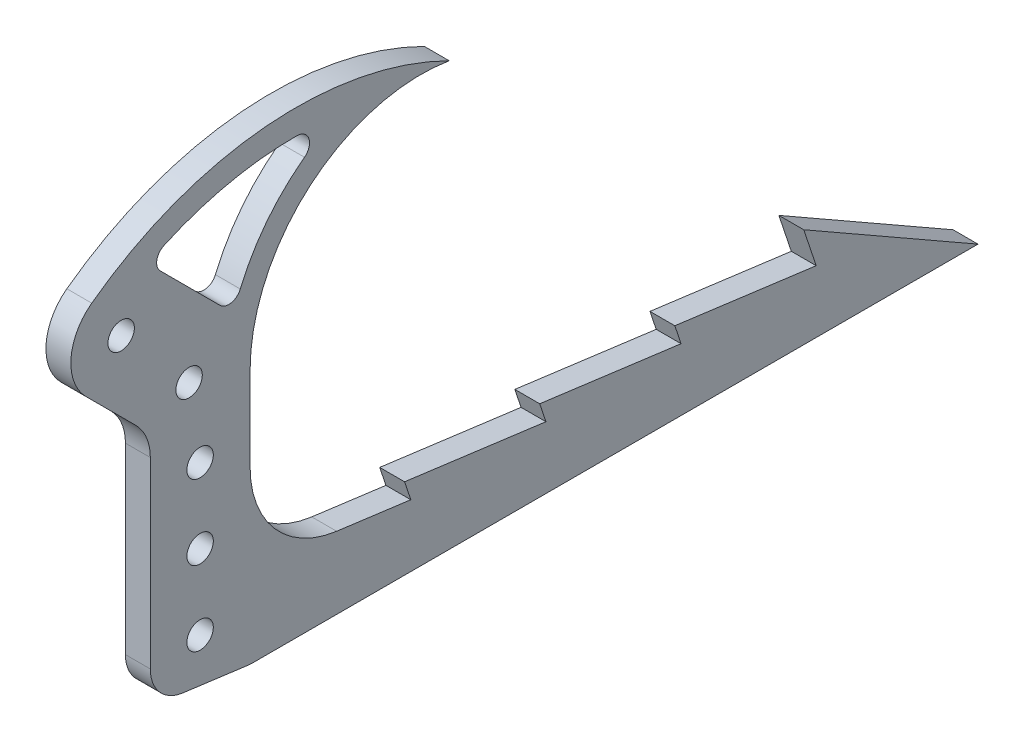
from build123d import *

# Parameters (mm, degrees)
SKETCH1_R                   = 19.05
BOSS_EXTRUDE1_DEPTH         = 12.7
FILLET1_R                   = 25.4
FILLET2_R                   = 50.8
F_1_2_CLEARANCE_HOLE1_D     = 13.49248
F_1_2_CLEARANCE_HOLE1_DEPTH = 38.1
F_1_2_CLEARANCE_HOLE1_TIP   = 4.053549943
SKETCH4_R                   = 19.05
CUT_EXTRUDE1_DEPTH          = 13.7
BOSS_EXTRUDE2_DEPTH         = 12.7
FILLET3_R                   = 19.05
FILLET4_R                   = 50.8
BOSS_EXTRUDE3_DEPTH         = 12.7
CUT_EXTRUDE2_DEPTH          = 13.7
FILLET7_R                   = 6.35


with BuildPart() as part:
    # Sketch1 → Boss-Extrude1 (new body)
    with BuildSketch(Plane(origin=(0, 0, 0), x_dir=(0, 0, -1), z_dir=(1, 0, 0))):
        with BuildLine():
            Line((390.630407277, -109.766978243), (305.29908743, -24.435658396))
            Line((305.29908743, -24.435658396), (12.395871839, 49.264412727))
            ThreePointArc((12.395871839, 49.264412727), (-49.470959365, 11.544010545), (-10.688712274, -49.662777107))
            Line((-10.688712274, -49.662777107), (281.610658396, -75.235658396))
            Line((281.610658396, -75.235658396), (339.725, -133.35))
            Line((339.725, -133.35), (339.725, -254))
            Line((339.725, -254), (390.630407277, -254))
            Line((390.630407277, -254), (390.630407277, -109.766978243))
        make_face()
        Circle(SKETCH1_R, mode=Mode.SUBTRACT)
    extrude(amount=BOSS_EXTRUDE1_DEPTH)

    # Fillet1
    fillet1_edges = [part.edges().sort_by_distance(p)[0] for p in [
        (6.35, -133.35, -339.725),
        (6.35, -75.235658396, -281.610658396),
    ]]
    fillet(fillet1_edges, radius=FILLET1_R)

    # Fillet2
    fillet2_edges = [part.edges().sort_by_distance(p)[0] for p in [
        (6.35, -24.435658396, -305.29908743),
        (6.35, -109.766978243, -390.630407277),
    ]]
    fillet(fillet2_edges, radius=FILLET2_R)

    # 1/2 Clearance Hole1
    with Locations(Plane(origin=(12.7, 0, 0), x_dir=(0, 0, -1), z_dir=(1, 0, 0))):
        with Locations((365.125, -234.95), (365.125, -196.85), (365.125, -158.75), (359.5071206, -120.65), (324.846024484, -82.55)):
            Hole(F_1_2_CLEARANCE_HOLE1_D / 2, depth=F_1_2_CLEARANCE_HOLE1_DEPTH)
            with Locations((0, 0, -(F_1_2_CLEARANCE_HOLE1_DEPTH + F_1_2_CLEARANCE_HOLE1_TIP / 2))):  # 118° drill point
                Cone(0, F_1_2_CLEARANCE_HOLE1_D / 2, F_1_2_CLEARANCE_HOLE1_TIP, mode=Mode.SUBTRACT)

    # Sketch4 → Cut-Extrude1 (cut, through all)
    with BuildSketch(Plane(origin=(12.7, 0, 0), x_dir=(0, 0, -1), z_dir=(1, 0, 0))):
        with BuildLine():
            Line((288.147750244, -81.772750244), (306.885512242, -100.510512242))
            ThreePointArc((306.885512242, -100.510512242), (306.885512242, -63.266297725), (344.129726759, -63.266297725))
            Line((344.129726759, -63.266297725), (315.219181895, -34.355752861))
            ThreePointArc((315.219181895, -34.355752861), (304.360921026, -26.089699144), (291.69402925, -21.012364618))
            Line((291.69402925, -21.012364618), (12.395871839, 49.264412727))
            ThreePointArc((12.395871839, 49.264412727), (-49.470959365, 11.544010545), (-10.688712274, -49.662777107))
            Line((-10.688712274, -49.662777107), (272.400993868, -74.429917155))
            ThreePointArc((272.400993868, -74.429917155), (280.92174185, -76.713044696), (288.147750244, -81.772750244))
        make_face()
        Circle(SKETCH4_R, mode=Mode.SUBTRACT)
    extrude(amount=-CUT_EXTRUDE1_DEPTH, mode=Mode.SUBTRACT)

    # Sketch5 → Boss-Extrude2 (add)
    with BuildSketch(Plane(origin=(12.7, 0, 0), x_dir=(0, 0, -1), z_dir=(1, 0, 0))):
        Polygon((339.725, -254), (390.630407277, -260.723431786), (762, -260.723431786), (673.1, -209.923431786), (679.45, -228.973431786), (607.332959214, -219.448431786), (610.507959214, -228.973431786), (538.390918427, -219.448431786), (541.565918427, -228.973431786), (469.448877641, -219.448431786), (472.623877641, -228.973431786), (400.506836855, -219.448431786), (390.630407277, -218.143982925), (390.630407277, -254), align=None)
    extrude(amount=-BOSS_EXTRUDE2_DEPTH)

    # Fillet3
    fillet3_edges = [part.edges().sort_by_distance(p)[0] for p in [
        (6.35, -260.723431786, -390.630407277),
        (6.35, -254, -339.725),
    ]]
    fillet(fillet3_edges, radius=FILLET3_R)

    # Fillet4
    fillet4_edges = [part.edges().sort_by_distance(p)[0] for p in [
        (6.35, -218.143982925, -390.630407277),
    ]]
    fillet(fillet4_edges, radius=FILLET4_R)

    # Sketch6 → Boss-Extrude3 (add)
    with BuildSketch(Plane(origin=(12.7, 0, 0), x_dir=(0, 0, -1), z_dir=(1, 0, 0))):
        with BuildLine():
            Line((375.751431761, -94.888002727), (344.129726759, -63.266297725))
            Line((344.129726759, -63.266297725), (309.842868861, -60.718111058))
            ThreePointArc((309.842868861, -60.718111058), (398.793863401, -27.03548328), (492.230407277, -44.823431786))
            ThreePointArc((492.230407277, -44.823431786), (421.492844328, -64.2581395), (390.630407277, -130.809027211))
            Line((390.630407277, -130.809027211), (375.751431761, -94.888002727))
        make_face()
    extrude(amount=-BOSS_EXTRUDE3_DEPTH)

    # Sketch7 → Cut-Extrude2 (cut, through all)
    with BuildSketch(Plane(origin=(12.7, 0, 0), x_dir=(0, 0, -1), z_dir=(1, 0, 0))):
        with BuildLine():
            Line((338.534408325, -57.67097929), (375.751431761, -94.888002727))
            ThreePointArc((375.751431761, -94.888002727), (379.072218132, -98.54883067), (382.021527149, -102.515045449))
            ThreePointArc((382.021527149, -102.515045449), (401.979554881, -65.801657117), (435.210476685, -40.465880242))
            ThreePointArc((435.210476685, -40.465880242), (385.540929372, -41.58660974), (338.534408325, -57.67097929))
        make_face()
    extrude(amount=-CUT_EXTRUDE2_DEPTH, mode=Mode.SUBTRACT)

    # Fillet7
    fillet7_edges = [part.edges().sort_by_distance(p)[0] for p in [
        (6.35, -102.515045449, -382.021527149),
        (6.35, -40.465880242, -435.210476685),
        (6.35, -57.67097929, -338.534408325),
    ]]
    fillet(fillet7_edges, radius=FILLET7_R)


solid = part.part
